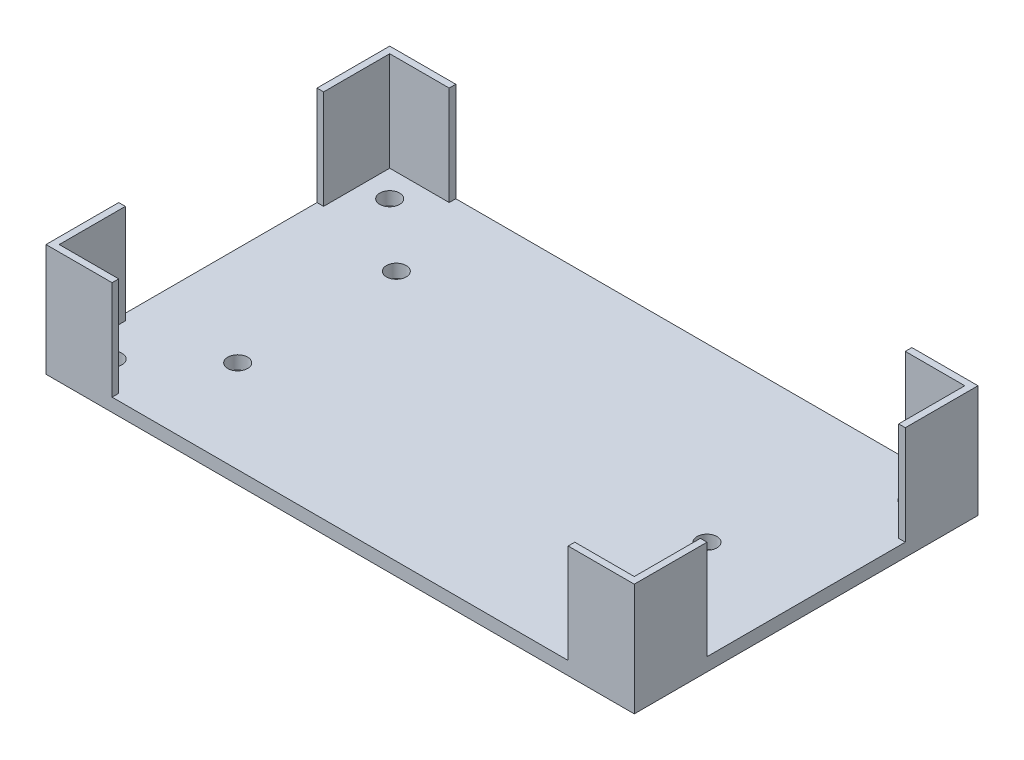
from build123d import *

# Parameters (mm, degrees)
SKETCH1_W           = 89
SKETCH1_H           = 52
BOSS_EXTRUDE1_DEPTH = 2
SKETCH2_R           = 1.5
CUT_EXTRUDE1_DEPTH  = 3
SKETCH5_R           = 1.5
CUT_EXTRUDE3_DEPTH  = 3
BOSS_EXTRUDE3_DEPTH = 15


with BuildPart() as part:
    # Sketch1 → Boss-Extrude1 (new body)
    with BuildSketch(Plane(origin=(0, 0, 0), x_dir=(1, 0, 0), z_dir=(0, 1, 0))):
        with Locations((-15.729105331, -13.267137121)):
            Rectangle(SKETCH1_W, SKETCH1_H)
    extrude(amount=BOSS_EXTRUDE1_DEPTH)

    # Sketch2 → Cut-Extrude1 (cut, through all)
    with BuildSketch(Plane(origin=(0, 2, 0), x_dir=(1, 0, 0), z_dir=(0, 1, 0))):
        with Locations((-55.229105331, -34.267137121)):
            Circle(SKETCH2_R)
        with Locations((-55.229105331, 7.732862879)):
            Circle(SKETCH2_R)
        with Locations((23.770894669, 7.732862879)):
            Circle(SKETCH2_R)
        with Locations((23.770894669, -34.267137121)):
            Circle(SKETCH2_R)
    extrude(amount=-CUT_EXTRUDE1_DEPTH, mode=Mode.SUBTRACT)

    # Sketch5 → Cut-Extrude3 (cut, through all)
    with BuildSketch(Plane(origin=(0, 2, 0), x_dir=(1, 0, 0), z_dir=(0, 1, 0))):
        with Locations((-45.229105331, -25.267137121)):
            Circle(SKETCH5_R)
        with Locations((-45.229105331, -1.267137121)):
            Circle(SKETCH5_R)
        with Locations((13.770894669, -13.267137121)):
            Circle(SKETCH5_R)
    extrude(amount=-CUT_EXTRUDE3_DEPTH, mode=Mode.SUBTRACT)

    # Sketch6 → Boss-Extrude3 (add)
    with BuildSketch(Plane(origin=(0, 2, 0), x_dir=(1, 0, 0), z_dir=(0, 1, 0))):
        Polygon((-60.229105331, -28.267137121), (-60.229105331, -39.267137121), (-50.229105331, -39.267137121), (-50.229105331, -38.267137121), (-59.229105331, -38.267137121), (-59.229105331, -28.267137121), align=None)
        Polygon((-60.229105331, 1.732862879), (-59.229105331, 1.732862879), (-59.229105331, 11.732862879), (-50.229105331, 11.732862879), (-50.229105331, 12.732862879), (-60.229105331, 12.732862879), align=None)
        Polygon((27.770894669, -28.267137121), (27.770894669, -38.267137121), (18.770894669, -38.267137121), (18.770894669, -39.267137121), (28.770894669, -39.267137121), (28.770894669, -28.267137121), align=None)
        Polygon((27.770894669, 11.732862879), (27.770894669, 1.732862879), (28.770894669, 1.732862879), (28.770894669, 12.732862879), (18.770894669, 12.732862879), (18.770894669, 11.732862879), align=None)
    extrude(amount=BOSS_EXTRUDE3_DEPTH)


solid = part.part
